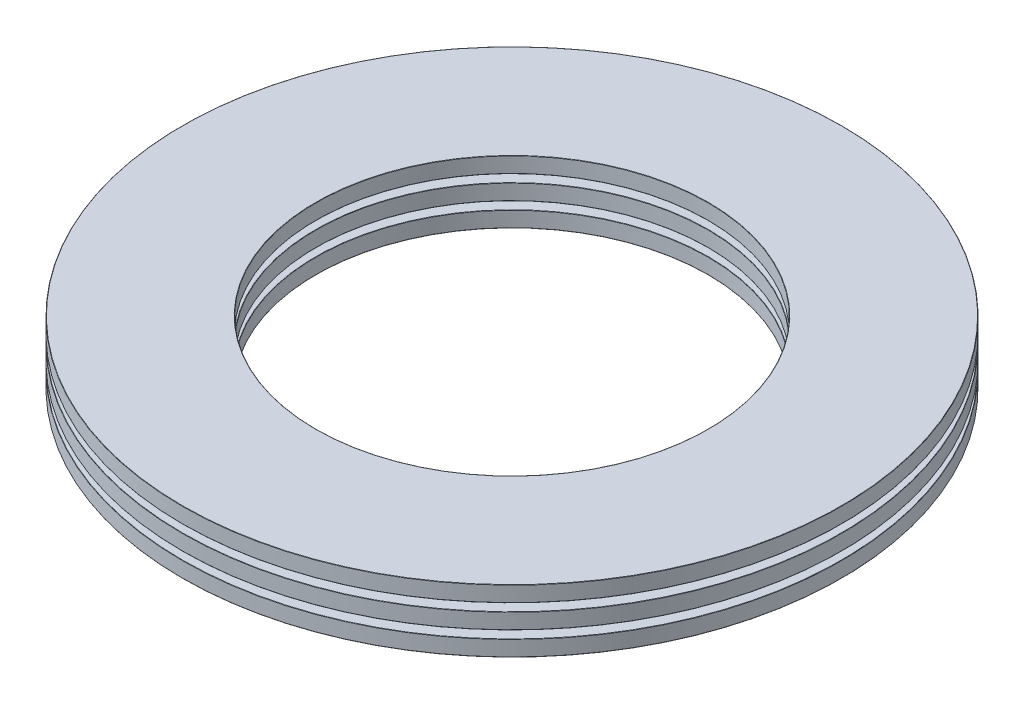
from build123d import *

# Parameters (mm, degrees)
SKETCH1_W         = 8.5
SKETCH1_H         = 1
SKETCH3_W         = 6.375
SKETCH3_H         = 1
SKETCH2_W         = 6.375
SKETCH2_H         = 1
CIRPATTERN1_COUNT = 16
CIRPATTERN2_COUNT = 16
SKETCH4_W         = 8.5
SKETCH4_H         = 1
FILLET1_R         = 0.02
FILLET2_R         = 0.02
FILLET3_R         = 0.02


with BuildPart() as part:
    # Sketch1 → Revolve1 (revolve)
    with BuildSketch(Plane(origin=(0, 0, 0), x_dir=(0, 0, -1), z_dir=(1, 0, 0))):
        with Locations((-16.75, 0)):
            Rectangle(SKETCH1_W, SKETCH1_H)
    revolve(axis=Axis((0, -1, 0), (0, 1, 0)))

    # Sketch3 → Cut-Revolve1 (revolve, cut)
    with BuildSketch(Plane(origin=(0, 0, 0), x_dir=(0, 0, -1), z_dir=(1, 0, 0))):
        with Locations((-16.75, 0.5)):
            Rectangle(SKETCH3_W, SKETCH3_H)
    cut_revolve1 = revolve(axis=Axis((0, 0, 19.9375), (0, 0, -1)), mode=Mode.SUBTRACT)

    # CirPattern2: Cut-Revolve1 ×16 about axis
    cirpattern2_axis = Axis((0, 1, 0), (0, -1, 0))
    for i in range(1, CIRPATTERN2_COUNT):
        add(cut_revolve1.rotate(cirpattern2_axis, i * 360 / CIRPATTERN2_COUNT), mode=Mode.SUBTRACT)

    # Fillet2
    fillet2_edges = [part.edges().sort_by_distance(p)[0] for p in [
        (0, -0.5, -12.5),
        (0, 0.5, -12.5),
        (0, -0.5, -21),
        (0, 0.5, -21),
    ]]
    fillet(fillet2_edges, radius=FILLET2_R)


with BuildPart() as body_2:
    # Sketch2 → Revolve2 (revolve)
    with BuildSketch(Plane(origin=(0, 0, 0), x_dir=(0, 0, -1), z_dir=(1, 0, 0))):
        with Locations((-16.75, 0.5)):
            Rectangle(SKETCH2_W, SKETCH2_H)
    revolve(axis=Axis((0, 0, 19.9375), (0, 0, -1)))


with BuildPart() as cirpattern1_1:
    # CirPattern1: pattern copy
    add(body_2.part.rotate(Axis((0, 1, 0), (0, -1, 0)), 1 * 360 / CIRPATTERN1_COUNT))


with BuildPart() as cirpattern1_2:
    # CirPattern1: pattern copy
    add(body_2.part.rotate(Axis((0, 1, 0), (0, -1, 0)), 2 * 360 / CIRPATTERN1_COUNT))


with BuildPart() as cirpattern1_3:
    # CirPattern1: pattern copy
    add(body_2.part.rotate(Axis((0, 1, 0), (0, -1, 0)), 3 * 360 / CIRPATTERN1_COUNT))


with BuildPart() as cirpattern1_4:
    # CirPattern1: pattern copy
    add(body_2.part.rotate(Axis((0, 1, 0), (0, -1, 0)), 4 * 360 / CIRPATTERN1_COUNT))


with BuildPart() as cirpattern1_5:
    # CirPattern1: pattern copy
    add(body_2.part.rotate(Axis((0, 1, 0), (0, -1, 0)), 5 * 360 / CIRPATTERN1_COUNT))


with BuildPart() as cirpattern1_6:
    # CirPattern1: pattern copy
    add(body_2.part.rotate(Axis((0, 1, 0), (0, -1, 0)), 6 * 360 / CIRPATTERN1_COUNT))


with BuildPart() as cirpattern1_7:
    # CirPattern1: pattern copy
    add(body_2.part.rotate(Axis((0, 1, 0), (0, -1, 0)), 7 * 360 / CIRPATTERN1_COUNT))


with BuildPart() as cirpattern1_8:
    # CirPattern1: pattern copy
    add(body_2.part.rotate(Axis((0, 1, 0), (0, -1, 0)), 8 * 360 / CIRPATTERN1_COUNT))


with BuildPart() as cirpattern1_9:
    # CirPattern1: pattern copy
    add(body_2.part.rotate(Axis((0, 1, 0), (0, -1, 0)), 9 * 360 / CIRPATTERN1_COUNT))


with BuildPart() as cirpattern1_10:
    # CirPattern1: pattern copy
    add(body_2.part.rotate(Axis((0, 1, 0), (0, -1, 0)), 10 * 360 / CIRPATTERN1_COUNT))


with BuildPart() as cirpattern1_11:
    # CirPattern1: pattern copy
    add(body_2.part.rotate(Axis((0, 1, 0), (0, -1, 0)), 11 * 360 / CIRPATTERN1_COUNT))


with BuildPart() as cirpattern1_12:
    # CirPattern1: pattern copy
    add(body_2.part.rotate(Axis((0, 1, 0), (0, -1, 0)), 12 * 360 / CIRPATTERN1_COUNT))


with BuildPart() as cirpattern1_13:
    # CirPattern1: pattern copy
    add(body_2.part.rotate(Axis((0, 1, 0), (0, -1, 0)), 13 * 360 / CIRPATTERN1_COUNT))


with BuildPart() as cirpattern1_14:
    # CirPattern1: pattern copy
    add(body_2.part.rotate(Axis((0, 1, 0), (0, -1, 0)), 14 * 360 / CIRPATTERN1_COUNT))


with BuildPart() as cirpattern1_15:
    # CirPattern1: pattern copy
    add(body_2.part.rotate(Axis((0, 1, 0), (0, -1, 0)), 15 * 360 / CIRPATTERN1_COUNT))


with BuildPart() as body_18:
    # Sketch4 → Revolve3 (revolve)
    with BuildSketch(Plane(origin=(0, 0, 0), x_dir=(0, 0, -1), z_dir=(1, 0, 0))):
        with Locations((-16.75, 1.499)):
            Rectangle(SKETCH4_W, SKETCH4_H)
        with Locations((-16.75, -1.499)):
            Rectangle(SKETCH4_W, SKETCH4_H)
    revolve(axis=Axis((0, -1, 0), (0, 1, 0)))

    # Fillet1
    fillet1_edges = [body_18.edges().sort_by_distance(p)[0] for p in [
        (0, 0.999, -12.5),
        (0, 1.999, -12.5),
        (0, 0.999, -21),
        (0, 1.999, -21),
    ]]
    fillet(fillet1_edges, radius=FILLET1_R)

    # Fillet3
    fillet3_edges = [body_18.edges().sort_by_distance(p)[0] for p in [
        (0, -1.999, -12.5),
        (0, -0.999, -12.5),
        (0, -1.999, -21),
        (0, -0.999, -21),
    ]]
    fillet(fillet3_edges, radius=FILLET3_R)


solid = Compound([part.part, body_2.part, cirpattern1_1.part, cirpattern1_2.part, cirpattern1_3.part, cirpattern1_4.part, cirpattern1_5.part, cirpattern1_6.part, cirpattern1_7.part, cirpattern1_8.part, cirpattern1_9.part, cirpattern1_10.part, cirpattern1_11.part, cirpattern1_12.part, cirpattern1_13.part, cirpattern1_14.part, cirpattern1_15.part, body_18.part])
